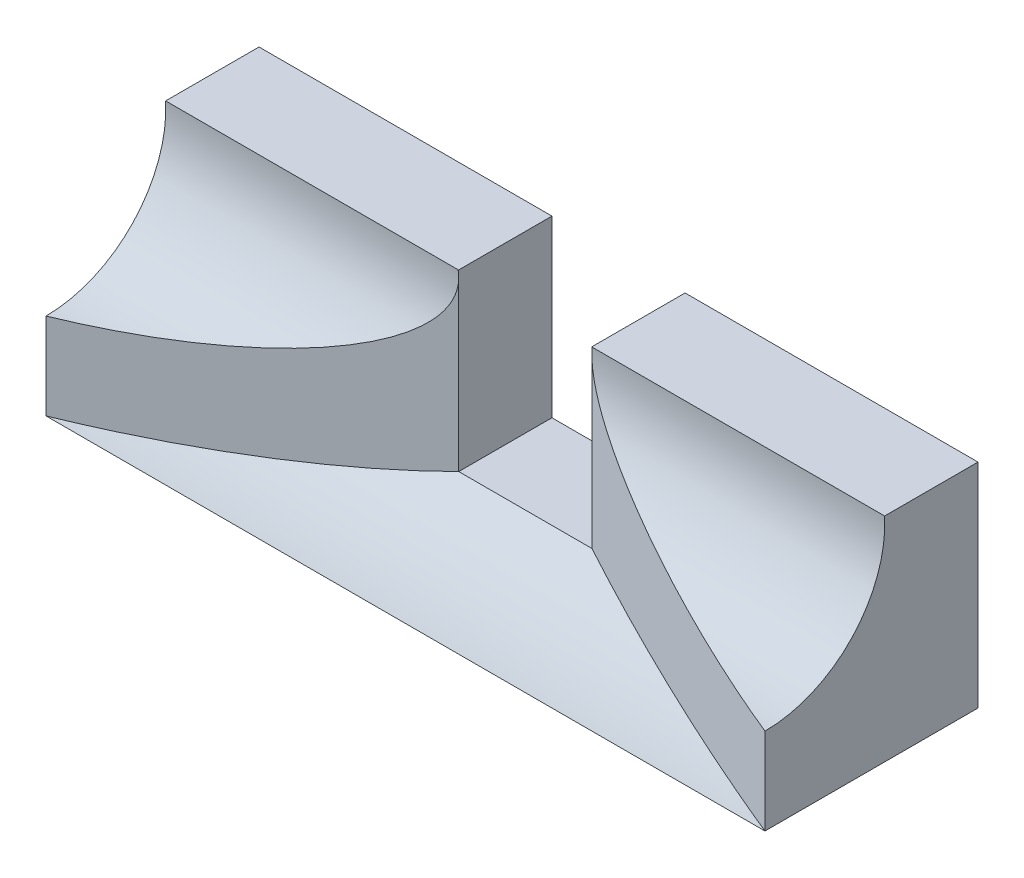
from build123d import *

# Parameters (mm, degrees)
SKETCH1_W           = 270
SKETCH1_H           = 80
BOSS_EXTRUDE1_DEPTH = 80
CUT_EXTRUDE1_DEPTH  = 81
BOSS_EXTRUDE2_DEPTH = 270
SKETCH3_R           = 45
CUT_EXTRUDE2_DEPTH  = 271
SKETCH5_W           = 50
SKETCH5_H           = 65.597147321
CUT_EXTRUDE3_DEPTH  = 36


with BuildPart() as part:
    # Sketch1 → Boss-Extrude1 (new body)
    with BuildSketch(Plane(origin=(0, 0, 0), x_dir=(1, 0, 0), z_dir=(0, 1, 0))):
        Rectangle(SKETCH1_W, SKETCH1_H)
    extrude(amount=BOSS_EXTRUDE1_DEPTH)

    # Sketch2 → Cut-Extrude1 (cut, through all)
    with BuildSketch(Plane(origin=(0, 80, 0), x_dir=(1, 0, 0), z_dir=(0, 1, 0))):
        Polygon((0, -40), (0, 5), (-25, 5), (-135, -40), align=None)
        Polygon((135, -40), (25, 5), (0, 5), (0, -40), align=None)
    extrude(amount=-CUT_EXTRUDE1_DEPTH, mode=Mode.SUBTRACT)

    # Sketch4 → Boss-Extrude2 (add)
    with BuildSketch(Plane(origin=(135, 0, 0), x_dir=(0, 0, -1), z_dir=(1, 0, 0))):
        with BuildLine():
            Line((40, 80), (37.459666924, 80))
            ThreePointArc((37.459666924, 80), (15.677643628, 23.590353368), (-40, 0))
            Line((-40, 0), (40, 0))
            Line((40, 0), (40, 80))
        make_face()
    extrude(amount=-BOSS_EXTRUDE2_DEPTH)

    # Sketch3 → Cut-Extrude2 (cut, through all)
    with BuildSketch(Plane(origin=(135, 0, 0), x_dir=(0, 0, -1), z_dir=(1, 0, 0))):
        with Locations((-40, 77.5)):
            Circle(SKETCH3_R)
    extrude(amount=-CUT_EXTRUDE2_DEPTH, mode=Mode.SUBTRACT)

    # Sketch5 → Cut-Extrude3 (cut, through all)
    with BuildSketch(Plane.XY.offset(-5)):
        with Locations((0, 47.20142634)):
            Rectangle(SKETCH5_W, SKETCH5_H)
    extrude(amount=-CUT_EXTRUDE3_DEPTH, mode=Mode.SUBTRACT)


solid = part.part
